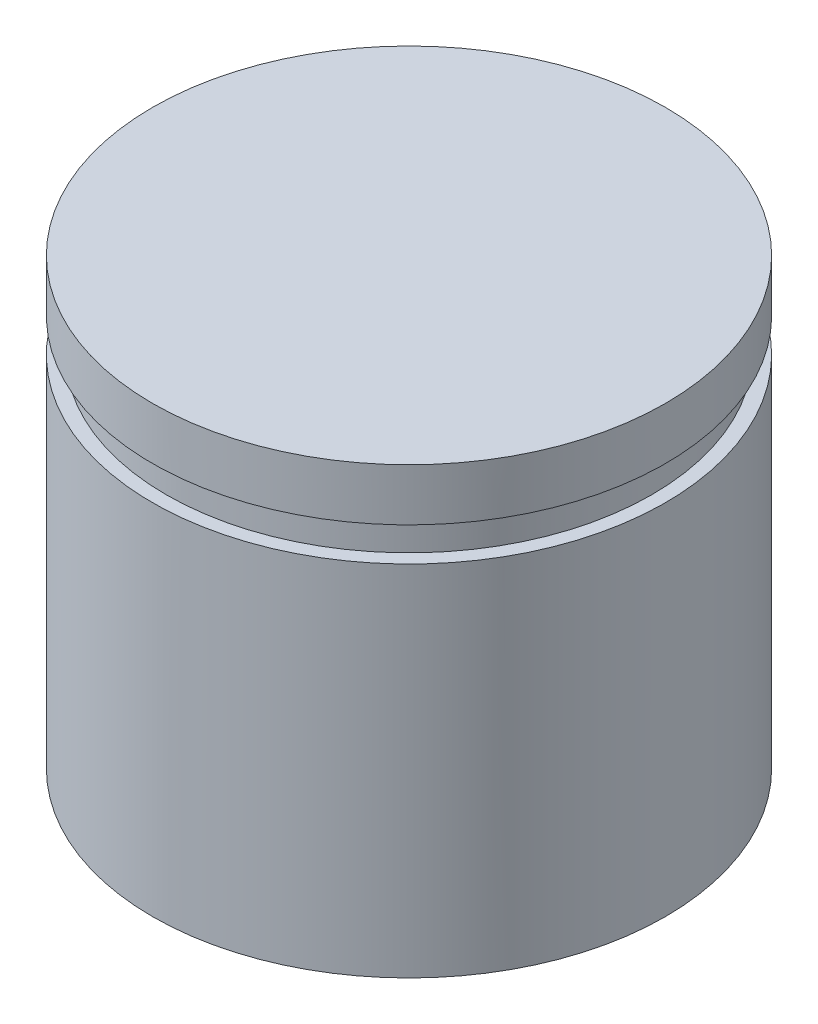
from build123d import *

# Parameters (mm, degrees)
SKETCH1_R           = 7.5
BOSS_EXTRUDE1_DEPTH = 13
SKETCH2_R           = 7.0993
CUT_EXTRUDE1_DEPTH  = 0.9906


with BuildPart() as part:
    # Sketch1 → Boss-Extrude1 (new body)
    with BuildSketch(Plane(origin=(0, 0, 0), x_dir=(1, 0, 0), z_dir=(0, 1, 0))):
        Circle(SKETCH1_R)
    extrude(amount=BOSS_EXTRUDE1_DEPTH)

    # Sketch2 → Cut-Extrude1 (cut)
    with BuildSketch(Plane(origin=(0, 11.476, 0), x_dir=(1, 0, 0), z_dir=(0, 1, 0))):
        Polygon((-10.537332024, 10.483478538), (-10.860452938, -10.950208747), (14.271173695, -10.950208747), (12.440155183, 11.524645927), align=None)
        Circle(SKETCH2_R, mode=Mode.SUBTRACT)
    extrude(amount=-CUT_EXTRUDE1_DEPTH, mode=Mode.SUBTRACT)


solid = part.part
